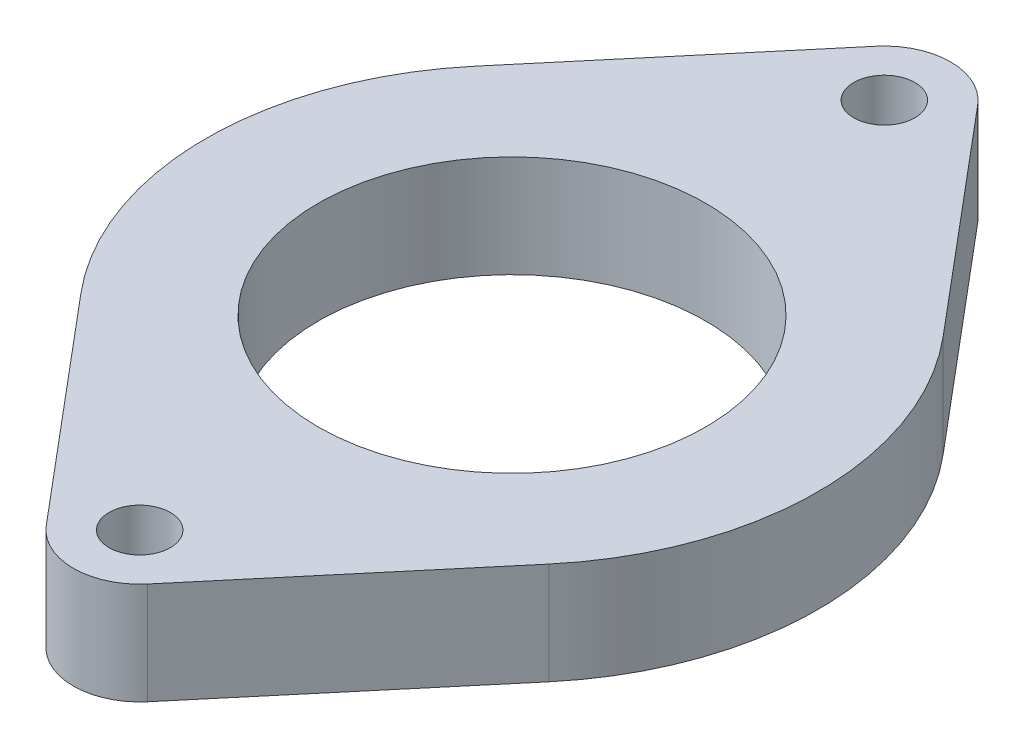
from build123d import *

# Parameters (mm, degrees)
SKETCH1_R           = 1.5
SKETCH1_R_2         = 9.5
BOSS_EXTRUDE1_DEPTH = 5


with BuildPart() as part:
    # Sketch1 → Boss-Extrude1 (new body)
    with BuildSketch(Plane(origin=(0, 0, 0), x_dir=(1, 0, 0), z_dir=(0, 1, 0))):
        with BuildLine():
            Line((-11.47745757, -9.657534247), (-2.486782474, -20.342465753))
            ThreePointArc((-2.486782474, -20.342465753), (0, -21.5), (2.486782474, -20.342465753))
            Line((2.486782474, -20.342465753), (11.47745757, -9.657534247))
            ThreePointArc((11.47745757, -9.657534247), (15, 0), (11.47745757, 9.657534247))
            Line((11.47745757, 9.657534247), (2.486782474, 20.342465753))
            ThreePointArc((2.486782474, 20.342465753), (0, 21.5), (-2.486782474, 20.342465753))
            Line((-2.486782474, 20.342465753), (-11.47745757, 9.657534247))
            ThreePointArc((-11.47745757, 9.657534247), (-15, 0), (-11.47745757, -9.657534247))
        make_face()
        with Locations((0, -18.25)):
            Circle(SKETCH1_R, mode=Mode.SUBTRACT)
        Circle(SKETCH1_R_2, mode=Mode.SUBTRACT)
        with Locations((0, 18.25)):
            Circle(SKETCH1_R, mode=Mode.SUBTRACT)
    extrude(amount=BOSS_EXTRUDE1_DEPTH)


solid = part.part
